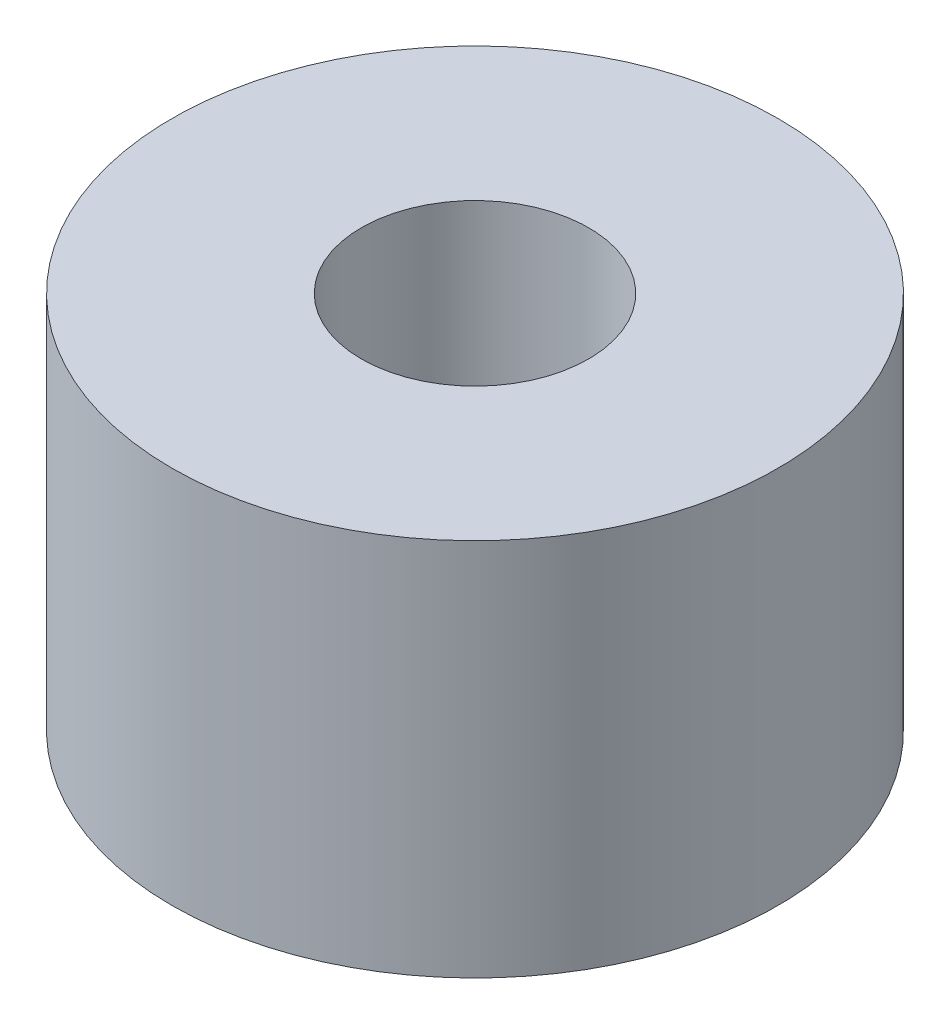
from build123d import *

# Parameters (mm, degrees)
SKETCH1_R           = 8
SKETCH1_R_2         = 3.002
BOSS_EXTRUDE1_DEPTH = 10


with BuildPart() as part:
    # Sketch1 → Boss-Extrude1 (new body)
    with BuildSketch(Plane(origin=(0, 0, 0), x_dir=(1, 0, 0), z_dir=(0, 1, 0))):
        Circle(SKETCH1_R)
        Circle(SKETCH1_R_2, mode=Mode.SUBTRACT)
    extrude(amount=BOSS_EXTRUDE1_DEPTH)


solid = part.part
